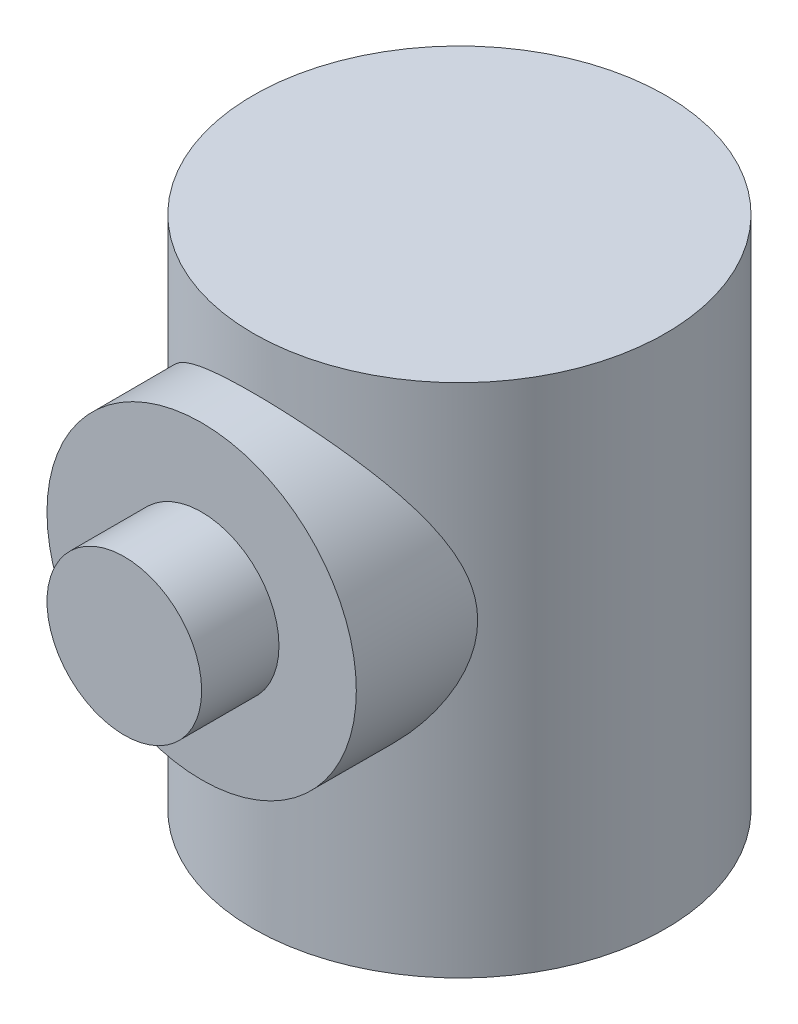
from build123d import *

# Parameters (mm, degrees)
SKETCH1_R           = 40
BOSS_EXTRUDE1_DEPTH = 100
SKETCH2_R           = 30
SKETCH2_R_2         = 15
BOSS_EXTRUDE2_DEPTH = 50
SKETCH1_3_R         = 15
CUT_EXTRUDE1_DEPTH  = 15
BOSS_EXTRUDE3_START = 50
SKETCH2_4_R         = 15
BOSS_EXTRUDE3_DEPTH = 15


with BuildPart() as part:
    # Sketch1 → Boss-Extrude1 (new body)
    with BuildSketch(Plane(origin=(0, 0, 0), x_dir=(1, 0, 0), z_dir=(0, 1, 0))):
        with Locations(Location((0, 0, 0), (0, 0, 270))):
            Circle(SKETCH1_R)
    extrude(amount=BOSS_EXTRUDE1_DEPTH)

    # Sketch2 → Boss-Extrude2 (add)
    with BuildSketch(Plane.XY):
        with Locations(Location((0, 60, 0), (0, 0, 180))):
            Circle(SKETCH2_R)
        with Locations((0, 60)):
            Circle(SKETCH2_R_2, mode=Mode.SUBTRACT)
        with Locations((0, 60)):
            Circle(SKETCH2_R_2)
    extrude(amount=BOSS_EXTRUDE2_DEPTH)

    # Sketch1_3 → Cut-Extrude1 (cut)
    with BuildSketch(Plane(origin=(0, 0, 0), x_dir=(1, 0, 0), z_dir=(0, 1, 0))):
        with Locations(Location((0, 0, 0), (0, 0, 270))):
            Circle(SKETCH1_3_R)
    extrude(amount=CUT_EXTRUDE1_DEPTH, mode=Mode.SUBTRACT)

    # Sketch2_4 → Boss-Extrude3 (add)
    with BuildSketch(Plane.XY.offset(BOSS_EXTRUDE3_START)):
        with Locations((0, 60)):
            Circle(SKETCH2_4_R)
    extrude(amount=BOSS_EXTRUDE3_DEPTH)


solid = part.part
